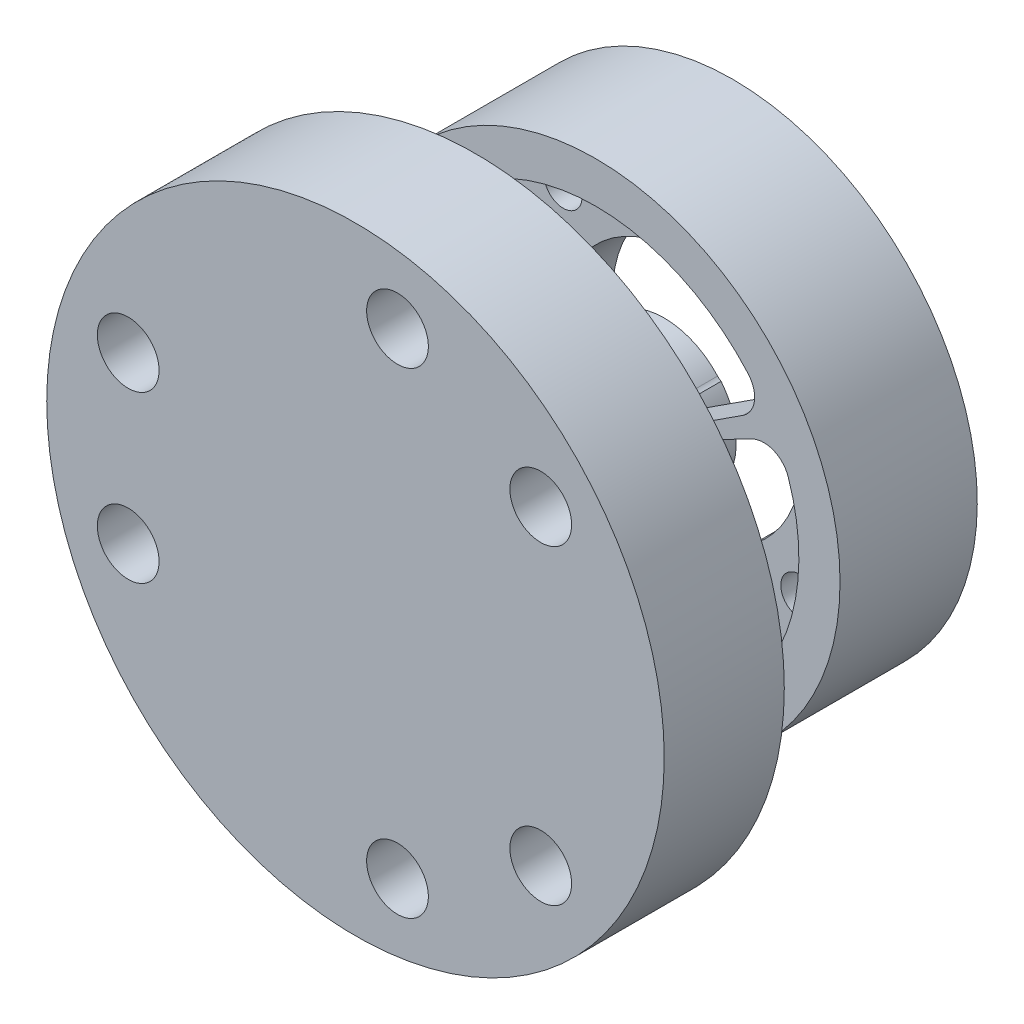
from build123d import *

# Parameters (mm, degrees)
SKETCH_1_R                   = 1.1
EXTRUDE_1_DEPTH              = 3
SKETCH_3_R                   = 14.25
SKETCH_3_R_2                 = 11.85
EXTRUDE_2_DEPTH              = 1
SKETCH_4_R                   = 14.25
EXTRUDE_3_DEPTH              = 4
SKETCH_5_R                   = 3.25
CUT_EXTRUDE_2_DEPTH          = 2.5
SKETCH_6_R                   = 3.5
EXTRUDE_4_DEPTH              = 7
SKETCH_10_R                  = 11.85
SKETCH_10_R_2                = 4.25
CUT_EXTRUDE_3_DEPTH          = 2
SKETCH_7_R                   = 18
SKETCH_7_R_2                 = 1.6
EXTRUDE_5_DEPTH              = 7
HOLE_WIZARD_M3_1_D           = 3.6
HOLE_WIZARD_M3_1_DEPTH       = 7
HOLE_WIZARD_M3_1_CSINK_D     = 6.3
HOLE_WIZARD_M3_1_CSINK_ANGLE = 90


with BuildPart() as part:
    # 스케치1 → 보스-돌출1 (new body)
    with BuildSketch(Plane.XY):
        with BuildLine():
            Line((-4.25, -5.562148865), (-4.25, -13.601470509))
            ThreePointArc((-4.25, -13.601470509), (0, 14.25), (4.25, -13.601470509))
            Line((4.25, -13.601470509), (4.25, -5.562148865))
            ThreePointArc((4.25, -5.562148865), (0, 7), (-4.25, -5.562148865))
        make_face()
        with Locations((6.894291117, 6.894291117)):
            Circle(SKETCH_1_R, mode=Mode.SUBTRACT)
        with Locations((6.894291117, -6.894291117)):
            Circle(SKETCH_1_R, mode=Mode.SUBTRACT)
        with Locations((-6.894291117, -6.894291117)):
            Circle(SKETCH_1_R, mode=Mode.SUBTRACT)
        with Locations((-6.894291117, 6.894291117)):
            Circle(SKETCH_1_R, mode=Mode.SUBTRACT)
    extrude(amount=EXTRUDE_1_DEPTH)

    # 스케치3 → 보스-돌출2 (add)
    with BuildSketch(Plane.XY.offset(3)):
        Circle(SKETCH_3_R)
        Circle(SKETCH_3_R_2, mode=Mode.SUBTRACT)
    extrude(amount=EXTRUDE_2_DEPTH)

    # 스케치4 → 보스-돌출3 (add)
    with BuildSketch(Plane.XY.offset(4)):
        Circle(SKETCH_4_R)
        with BuildLine():
            Line((-8.58859676, 5.577499951), (-4.139329935, 2.688112291))
            ThreePointArc((-4.139329935, 2.688112291), (-3.600629974, 2.565705616), (-3.111039714, 2.821600946))
            ThreePointArc((-3.111039714, 2.821600946), (0, 4.2), (3.111039714, 2.821600946))
            ThreePointArc((3.111039714, 2.821600946), (3.600629974, 2.565705616), (4.139329935, 2.688112291))
            Line((4.139329935, 2.688112291), (8.58859676, 5.577499951))
            ThreePointArc((8.58859676, 5.577499951), (9.257640836, 6.631064641), (8.897962585, 7.826158817))
            ThreePointArc((8.897962585, 7.826158817), (0, 11.85), (-8.897962585, 7.826158817))
            ThreePointArc((-8.897962585, 7.826158817), (-9.257640836, 6.631064641), (-8.58859676, 5.577499951))
        make_face(mode=Mode.SUBTRACT)
        with BuildLine():
            Line((0.535958267, -10.226692952), (0.258308564, -4.928821024))
            ThreePointArc((0.258308564, -4.928821024), (0.421651255, -4.401089835), (0.888058241, -4.105039897))
            ThreePointArc((0.888058241, -4.105039897), (3.637306696, -2.1), (3.999097955, 1.283438952))
            ThreePointArc((3.999097955, 1.283438952), (4.022281229, 1.835384219), (4.3976385, 2.240708733))
            Line((4.3976385, 2.240708733), (9.124555027, 4.649193001))
            ThreePointArc((9.124555027, 4.649193001), (10.371490851, 4.701819822), (11.226633642, 3.792782232))
            ThreePointArc((11.226633642, 3.792782232), (10.262401035, -5.925), (2.328671057, -11.618941049))
            ThreePointArc((2.328671057, -11.618941049), (1.113850016, -11.332884463), (0.535958267, -10.226692952))
        make_face(mode=Mode.SUBTRACT)
        with BuildLine():
            Line((-9.124555027, 4.649193001), (-4.3976385, 2.240708733))
            ThreePointArc((-4.3976385, 2.240708733), (-4.022281229, 1.835384219), (-3.999097955, 1.283438952))
            ThreePointArc((-3.999097955, 1.283438952), (-3.637306696, -2.1), (-0.888058241, -4.105039897))
            ThreePointArc((-0.888058241, -4.105039897), (-0.421651255, -4.401089835), (-0.258308564, -4.928821024))
            Line((-0.258308564, -4.928821024), (-0.535958267, -10.226692952))
            ThreePointArc((-0.535958267, -10.226692952), (-1.113850016, -11.332884463), (-2.328671057, -11.618941049))
            ThreePointArc((-2.328671057, -11.618941049), (-10.262401035, -5.925), (-11.226633642, 3.792782232))
            ThreePointArc((-11.226633642, 3.792782232), (-10.371490851, 4.701819822), (-9.124555027, 4.649193001))
        make_face(mode=Mode.SUBTRACT)
    extrude(amount=EXTRUDE_3_DEPTH)

    # 스케치5 → 컷-돌출2 (cut)
    with BuildSketch(Plane(origin=(0, 0, 4), x_dir=(-1, 0, 0), z_dir=(0, 0, -1))):
        Circle(SKETCH_5_R)
    extrude(amount=-CUT_EXTRUDE_2_DEPTH, mode=Mode.SUBTRACT)

    # 스케치6 → 보스-돌출4 (add)
    with BuildSketch(Plane.XY.offset(8)):
        Circle(SKETCH_6_R)
    extrude(amount=EXTRUDE_4_DEPTH)

    # 스케치10 → 컷-돌출3 (cut)
    with BuildSketch(Plane(origin=(0, 0, 4), x_dir=(-1, 0, 0), z_dir=(0, 0, -1))):
        Circle(SKETCH_10_R)
        Circle(SKETCH_10_R_2, mode=Mode.SUBTRACT)
    extrude(amount=-CUT_EXTRUDE_3_DEPTH, mode=Mode.SUBTRACT)

    # 스케치7 → 보스-돌출5 (add)
    with BuildSketch(Plane.XY.offset(15)):
        Circle(SKETCH_7_R)
        with Locations((-13.249665953, 4.822484021)):
            Circle(SKETCH_7_R_2, mode=Mode.SUBTRACT)
        with Locations((-13.249665953, -4.822484021)):
            Circle(SKETCH_7_R_2, mode=Mode.SUBTRACT)
        with Locations((10.801226648, 9.063305297)):
            Circle(SKETCH_7_R_2, mode=Mode.SUBTRACT)
        with Locations((2.448439305, 13.885789317)):
            Circle(SKETCH_7_R_2, mode=Mode.SUBTRACT)
        with Locations((2.448439305, -13.885789317)):
            Circle(SKETCH_7_R_2, mode=Mode.SUBTRACT)
        with Locations((10.801226648, -9.063305297)):
            Circle(SKETCH_7_R_2, mode=Mode.SUBTRACT)
    extrude(amount=EXTRUDE_5_DEPTH)

    # M3 접시 머리 나사용 카운터싱크1
    with Locations(Plane(origin=(2.448439305, 13.885789317, 15), x_dir=(-1, 0, 0), z_dir=(0, 0, -1))):
        with Locations((0, 0), (15.698105258, -9.063305296), (15.698105258, -18.708273338), (0, -27.771578634), (-8.352787343, -22.949094614), (-8.352787343, -4.82248402)):
            CounterSinkHole(HOLE_WIZARD_M3_1_D / 2, HOLE_WIZARD_M3_1_CSINK_D / 2, depth=HOLE_WIZARD_M3_1_DEPTH, counter_sink_angle=HOLE_WIZARD_M3_1_CSINK_ANGLE)


solid = part.part
